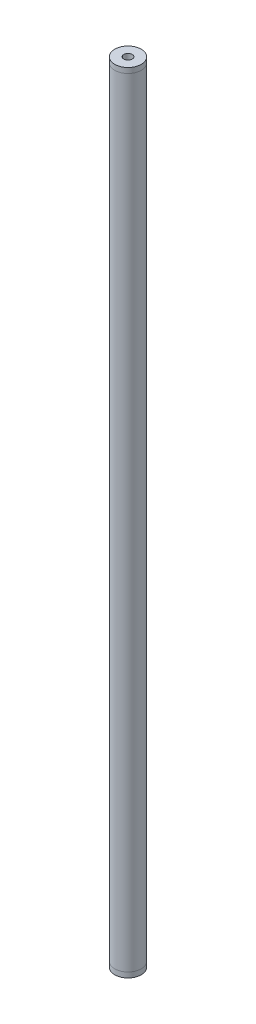
from build123d import *

# Parameters (mm, degrees)
ESBO_O1_R                = 25.4
ESBO_O1_R_2              = 21.65
RESSALTO_EXTRUS_O1_DEPTH = 1500


with BuildPart() as part:
    # Esboço1 → Ressalto-extrusão1 (new body)
    with BuildSketch(Plane(origin=(0, 0, 0), x_dir=(1, 0, 0), z_dir=(0, 1, 0))):
        Circle(ESBO_O1_R)
        Circle(ESBO_O1_R_2, mode=Mode.SUBTRACT)
    extrude(amount=RESSALTO_EXTRUS_O1_DEPTH)


with BuildPart() as body_2:
    # Esboço2 → Revolução1 (revolve)
    with BuildSketch(Plane.XY):
        Polygon((25.4, 1500), (25.4, 1510), (8, 1510), (8, 1460), (21.65, 1460), (21.65, 1500), align=None)
        Polygon((8, -10), (8, 40), (21.65, 40), (21.65, 0), (25.4, 0), (25.4, -10), align=None)
    revolve(axis=Axis((0, 0, 0), (0, 1, 0)))


solid = Compound([part.part, body_2.part])
